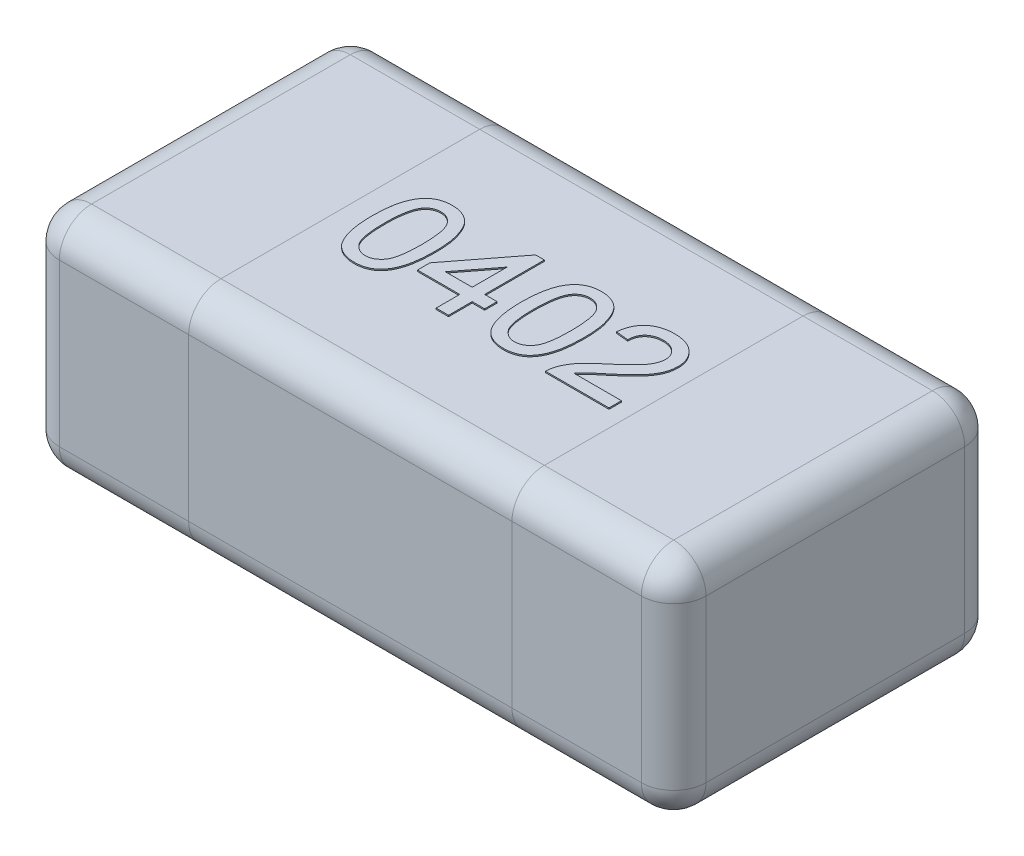
from build123d import *

# Parameters (mm, degrees)
SKETCH1_W      = 1
SKETCH1_H      = 0.5
EXTRUDE1_DEPTH = 0.35
FILLET1_R      = 0.05
EXTRUDE2_DEPTH = 0.002


with BuildPart() as part:
    # Sketch1 → Extrude1 (new body)
    with BuildSketch(Plane(origin=(0, 0, 0), x_dir=(1, 0, 0), z_dir=(0, 1, 0))):
        Rectangle(SKETCH1_W, SKETCH1_H)
    extrude(amount=EXTRUDE1_DEPTH)

    # Fillet1
    fillet1_edges = [part.edges().sort_by_distance(p)[0] for p in [
        (0.5, 0.35, 0),
        (0, 0.35, -0.25),
        (-0.5, 0.35, 0),
        (0, 0, -0.25),
        (0.5, 0, 0),
        (0, 0, 0.25),
        (-0.5, 0, 0),
        (0, 0.35, 0.25),
        (-0.5, 0.175, -0.25),
        (0.5, 0.175, -0.25),
        (0.5, 0.175, 0.25),
        (-0.5, 0.175, 0.25),
    ]]
    fillet(fillet1_edges, radius=FILLET1_R)

    # Sketch3 → Extrude2 (add)
    with BuildSketch(Plane(origin=(0, 0.35, 0), x_dir=(1, 0, 0), z_dir=(0, 1, 0))):
        with BuildLine():
            add(Edge.make_bspline(
                [(-0.215384615, -0.001021635), (-0.21536524, 0.001122003), (-0.215327293, 0.005320487), (-0.215091917, 0.011463622), (-0.21468097, 0.017297504), (-0.214067539, 0.022817065), (-0.213341122, 0.028034764), (-0.212396775, 0.032943155), (-0.211334247, 0.037553251), (-0.210059405, 0.041860246), (-0.20865877, 0.045901174), (-0.207069705, 0.04966955), (-0.205281792, 0.053161381), (-0.203382895, 0.056412877), (-0.201273053, 0.059373466), (-0.19907961, 0.062126232), (-0.196643162, 0.064570222), (-0.19406502, 0.06676832), (-0.191307221, 0.068708013), (-0.188384356, 0.070381735), (-0.185307672, 0.07185951), (-0.182018531, 0.072971978), (-0.178585214, 0.073878876), (-0.174981294, 0.074546001), (-0.171202799, 0.074939294), (-0.168620729, 0.074979536), (-0.167307692, 0.075)],
                knots=[0, 0, 0, 0, 6.431e-06, 1.2595e-05, 1.844e-05, 2.3971e-05, 2.9254e-05, 3.4239e-05, 3.8962e-05, 4.344e-05, 4.7707e-05, 5.1787e-05, 5.5698e-05, 5.947e-05, 6.3071e-05, 6.6596e-05, 7.0016e-05, 7.3406e-05, 7.6749e-05, 8.0114e-05, 8.3502e-05, 8.697e-05, 9.0512e-05, 9.4149e-05, 9.7955e-05, 0.000101893, 0.000101893, 0.000101893, 0.000101893], degree=3))
            add(Edge.make_bspline(
                [(-0.167307692, 0.075), (-0.165381297, 0.074943365), (-0.161596815, 0.074832104), (-0.156071453, 0.073924679), (-0.150864154, 0.072372388), (-0.145978304, 0.070278281), (-0.141497424, 0.067618363), (-0.137495809, 0.064384826), (-0.134016624, 0.060611623), (-0.131097837, 0.056254042), (-0.128546526, 0.051432296), (-0.126279998, 0.046124741), (-0.124231122, 0.040337325), (-0.122777195, 0.035156781), (-0.12174011, 0.030684751), (-0.121053643, 0.026996347), (-0.120483737, 0.023016538), (-0.120047112, 0.018754953), (-0.119688871, 0.014216372), (-0.119412219, 0.009397968), (-0.119271789, 0.004287698), (-0.119244699, 0.000781321), (-0.119230769, -0.001021635)],
                knots=[0, 0, 0, 0, 5.777e-06, 1.1349e-05, 1.674e-05, 2.2043e-05, 2.7258e-05, 3.2321e-05, 3.7425e-05, 4.2592e-05, 4.801e-05, 5.377e-05, 5.9891e-05, 6.6416e-05, 6.99e-05, 7.366e-05, 7.7668e-05, 8.1958e-05, 8.651e-05, 9.1325e-05, 9.6435e-05, 0.000101844, 0.000101844, 0.000101844, 0.000101844], degree=3))
            add(Edge.make_bspline(
                [(-0.119230769, -0.001021635), (-0.119250507, -0.003155203), (-0.119289069, -0.00732355), (-0.119518138, -0.013417428), (-0.119953848, -0.019207296), (-0.120489996, -0.024706416), (-0.121301077, -0.029900109), (-0.12217506, -0.034810441), (-0.123255962, -0.039415115), (-0.12451712, -0.043716149), (-0.12593747, -0.047736285), (-0.127495104, -0.051505906), (-0.129220334, -0.055022436), (-0.131164508, -0.058251575), (-0.133238671, -0.061236186), (-0.135458016, -0.063987464), (-0.137869594, -0.066465811), (-0.140470969, -0.068657315), (-0.143209405, -0.070631406), (-0.146139376, -0.072321652), (-0.149248057, -0.073721992), (-0.152514679, -0.074919212), (-0.155972386, -0.075796465), (-0.159593911, -0.076467989), (-0.163392598, -0.07686343), (-0.165984655, -0.07690292), (-0.167307692, -0.076923077)],
                knots=[0, 0, 0, 0, 6.401e-06, 1.2505e-05, 1.829e-05, 2.3818e-05, 2.9075e-05, 3.4055e-05, 3.8778e-05, 4.3256e-05, 4.7495e-05, 5.1563e-05, 5.5487e-05, 5.9233e-05, 6.2859e-05, 6.6384e-05, 6.9826e-05, 7.3215e-05, 7.6576e-05, 7.9941e-05, 8.3343e-05, 8.6794e-05, 9.0365e-05, 9.4031e-05, 9.7837e-05, 0.000101805, 0.000101805, 0.000101805, 0.000101805], degree=3))
            add(Edge.make_bspline(
                [(-0.167307692, -0.076923077), (-0.169042347, -0.076873596), (-0.172424447, -0.076777121), (-0.177363754, -0.076121636), (-0.181999557, -0.074967951), (-0.186370957, -0.073420697), (-0.190428817, -0.071351156), (-0.194192513, -0.068833154), (-0.197737673, -0.065925277), (-0.199778482, -0.063631029), (-0.200811298, -0.062469952)],
                knots=[0, 0, 0, 0, 5.204e-06, 1.0146e-05, 1.4912e-05, 1.9513e-05, 2.4028e-05, 2.8537e-05, 3.308e-05, 3.7736e-05, 3.7736e-05, 3.7736e-05, 3.7736e-05], degree=3))
            add(Edge.make_bspline(
                [(-0.200811298, -0.062469952), (-0.202000093, -0.060755098), (-0.204451439, -0.057218995), (-0.207320527, -0.051189611), (-0.209879805, -0.044552107), (-0.211888368, -0.037176254), (-0.213461574, -0.029120757), (-0.214597822, -0.020369808), (-0.215240826, -0.010927188), (-0.215335604, -0.004398023), (-0.215384615, -0.001021635)],
                knots=[0, 0, 0, 0, 6.251e-06, 1.2889e-05, 1.9965e-05, 2.7576e-05, 3.5785e-05, 4.4573e-05, 5.4032e-05, 6.4161e-05, 6.4161e-05, 6.4161e-05, 6.4161e-05], degree=3))
        make_face()
        with BuildLine():
            add(Edge.make_bspline(
                [(-0.196153846, -0.000961538), (-0.196134752, -0.003846584), (-0.1960982, -0.009369199), (-0.195716327, -0.017259208), (-0.195058949, -0.024377073), (-0.194189852, -0.030712939), (-0.193042293, -0.036275377), (-0.191601396, -0.041050211), (-0.189977162, -0.045094751), (-0.187967204, -0.048358867), (-0.185766521, -0.051019598), (-0.183494467, -0.053307912), (-0.181097587, -0.055252927), (-0.178591522, -0.056874673), (-0.175937387, -0.058102553), (-0.173164205, -0.058992522), (-0.170271373, -0.059504686), (-0.168301222, -0.059578275), (-0.167307692, -0.059615385)],
                knots=[0, 0, 0, 0, 8.655e-06, 1.6567e-05, 2.3689e-05, 3.0093e-05, 3.5745e-05, 4.0706e-05, 4.5043e-05, 4.8779e-05, 5.2153e-05, 5.5383e-05, 5.8438e-05, 6.1397e-05, 6.4314e-05, 6.7184e-05, 7.0113e-05, 7.3094e-05, 7.3094e-05, 7.3094e-05, 7.3094e-05], degree=3))
            add(Edge.make_bspline(
                [(-0.167307692, -0.059615385), (-0.166314411, -0.059577464), (-0.164344754, -0.059502268), (-0.161445238, -0.059001397), (-0.158682846, -0.058065613), (-0.156032668, -0.05684207), (-0.153508388, -0.055257289), (-0.15112328, -0.053304927), (-0.148839257, -0.051017971), (-0.14664846, -0.048326314), (-0.144653815, -0.045047107), (-0.142999112, -0.041005862), (-0.141580671, -0.036222665), (-0.140426814, -0.030663062), (-0.139554132, -0.024337213), (-0.138900728, -0.01723909), (-0.1385163, -0.009359233), (-0.138480352, -0.003846597), (-0.138461538, -0.000961538)],
                knots=[0, 0, 0, 0, 2.98e-06, 5.91e-06, 8.789e-06, 1.1706e-05, 1.4649e-05, 1.7704e-05, 2.0934e-05, 2.4331e-05, 2.8093e-05, 3.2402e-05, 3.7392e-05, 4.3044e-05, 4.9418e-05, 5.654e-05, 6.4422e-05, 7.3077e-05, 7.3077e-05, 7.3077e-05, 7.3077e-05], degree=3))
            add(Edge.make_bspline(
                [(-0.138461538, -0.000961538), (-0.13847975, 0.001863491), (-0.138514642, 0.007276142), (-0.138908985, 0.015014149), (-0.139526956, 0.022012544), (-0.140372243, 0.028277777), (-0.141495628, 0.033803048), (-0.142858142, 0.038600117), (-0.144481781, 0.042658756), (-0.146412281, 0.046019733), (-0.148561315, 0.048776646), (-0.150806184, 0.051162994), (-0.153203011, 0.053192505), (-0.15579426, 0.054820609), (-0.15849641, 0.056134103), (-0.161371551, 0.057038082), (-0.164391421, 0.057593459), (-0.166463918, 0.057658982), (-0.167518029, 0.057692308)],
                knots=[0, 0, 0, 0, 8.474e-06, 1.6237e-05, 2.3236e-05, 2.9547e-05, 3.5192e-05, 4.0137e-05, 4.4489e-05, 4.8272e-05, 5.1722e-05, 5.4953e-05, 5.8088e-05, 6.1114e-05, 6.4111e-05, 6.7076e-05, 7.0129e-05, 7.329e-05, 7.329e-05, 7.329e-05, 7.329e-05], degree=3))
            add(Edge.make_bspline(
                [(-0.167518029, 0.057692308), (-0.168511496, 0.057666233), (-0.170470487, 0.057614817), (-0.173338706, 0.057124054), (-0.176056884, 0.056303389), (-0.178656161, 0.055191718), (-0.181071649, 0.053695629), (-0.18339914, 0.051948838), (-0.185529622, 0.049820569), (-0.186813432, 0.048229508), (-0.187469952, 0.047415865)],
                knots=[0, 0, 0, 0, 2.979e-06, 5.873e-06, 8.697e-06, 1.1482e-05, 1.4327e-05, 1.72e-05, 2.0196e-05, 2.3331e-05, 2.3331e-05, 2.3331e-05, 2.3331e-05], degree=3))
            add(Edge.make_bspline(
                [(-0.187469952, 0.047415865), (-0.188184701, 0.046220876), (-0.189694102, 0.043697311), (-0.191383033, 0.03931125), (-0.192874969, 0.034298818), (-0.194103326, 0.028582894), (-0.194991956, 0.022173284), (-0.195693496, 0.01507743), (-0.196057919, 0.007285427), (-0.196120988, 0.001863295), (-0.196153846, -0.000961538)],
                knots=[0, 0, 0, 0, 4.171e-06, 8.807e-06, 1.4046e-05, 1.9857e-05, 2.6324e-05, 3.3449e-05, 4.1242e-05, 4.9717e-05, 4.9717e-05, 4.9717e-05, 4.9717e-05], degree=3))
        make_face(mode=Mode.SUBTRACT)
        Polygon((-0.042307692, -0.075), (-0.042307692, -0.038461538), (-0.107692308, -0.038461538), (-0.107692308, -0.019230769), (-0.036538462, 0.073076923), (-0.023076923, 0.073076923), (-0.023076923, -0.019230769), (-0.003846154, -0.019230769), (-0.003846154, -0.038461538), (-0.023076923, -0.038461538), (-0.023076923, -0.075), align=None)
        Polygon((-0.042307692, -0.019230769), (-0.042307692, 0.034795673), (-0.083954327, -0.019230769), align=None, mode=Mode.SUBTRACT)
        with BuildLine():
            add(Edge.make_bspline(
                [(0.015384615, -0.001021635), (0.01540399, 0.001122003), (0.015441938, 0.005320487), (0.015677314, 0.011463622), (0.016088261, 0.017297504), (0.016701692, 0.022817065), (0.017428109, 0.028034764), (0.018372456, 0.032943155), (0.019434984, 0.037553251), (0.020709826, 0.041860246), (0.022110461, 0.045901174), (0.023699525, 0.04966955), (0.025487439, 0.053161381), (0.027386336, 0.056412877), (0.029496178, 0.059373466), (0.031689621, 0.062126232), (0.034126069, 0.064570222), (0.036704211, 0.06676832), (0.03946201, 0.068708013), (0.042384875, 0.070381735), (0.045461558, 0.07185951), (0.0487507, 0.072971978), (0.052184016, 0.073878876), (0.055787937, 0.074546001), (0.059566432, 0.074939294), (0.062148502, 0.074979536), (0.063461538, 0.075)],
                knots=[0, 0, 0, 0, 6.431e-06, 1.2595e-05, 1.844e-05, 2.3971e-05, 2.9254e-05, 3.4239e-05, 3.8962e-05, 4.344e-05, 4.7707e-05, 5.1787e-05, 5.5698e-05, 5.947e-05, 6.3071e-05, 6.6596e-05, 7.0016e-05, 7.3406e-05, 7.6749e-05, 8.0114e-05, 8.3502e-05, 8.697e-05, 9.0512e-05, 9.4149e-05, 9.7955e-05, 0.000101893, 0.000101893, 0.000101893, 0.000101893], degree=3))
            add(Edge.make_bspline(
                [(0.063461538, 0.075), (0.065387934, 0.074943365), (0.069172416, 0.074832104), (0.074697778, 0.073924679), (0.079905076, 0.072372388), (0.084790927, 0.070278281), (0.089271807, 0.067618363), (0.093273422, 0.064384826), (0.096752607, 0.060611623), (0.099671394, 0.056254042), (0.102222704, 0.051432296), (0.104489233, 0.046124741), (0.106538109, 0.040337325), (0.107992036, 0.035156781), (0.10902912, 0.030684751), (0.109715588, 0.026996347), (0.110285494, 0.023016538), (0.110722119, 0.018754953), (0.111080359, 0.014216372), (0.111357012, 0.009397968), (0.111497442, 0.004287698), (0.111524532, 0.000781321), (0.111538462, -0.001021635)],
                knots=[0, 0, 0, 0, 5.777e-06, 1.1349e-05, 1.674e-05, 2.2043e-05, 2.7258e-05, 3.2321e-05, 3.7425e-05, 4.2592e-05, 4.801e-05, 5.377e-05, 5.9891e-05, 6.6416e-05, 6.99e-05, 7.366e-05, 7.7668e-05, 8.1958e-05, 8.651e-05, 9.1325e-05, 9.6435e-05, 0.000101844, 0.000101844, 0.000101844, 0.000101844], degree=3))
            add(Edge.make_bspline(
                [(0.111538462, -0.001021635), (0.111518724, -0.003155203), (0.111480162, -0.00732355), (0.111251093, -0.013417428), (0.110815383, -0.019207296), (0.110279235, -0.024706416), (0.109468154, -0.029900109), (0.108594171, -0.034810441), (0.107513269, -0.039415115), (0.106252111, -0.043716149), (0.10483176, -0.047736285), (0.103274126, -0.051505906), (0.101548897, -0.055022436), (0.099604723, -0.058251575), (0.097530559, -0.061236186), (0.095311215, -0.063987464), (0.092899636, -0.066465811), (0.090298262, -0.068657315), (0.087559826, -0.070631406), (0.084629855, -0.072321652), (0.081521174, -0.073721992), (0.078254552, -0.074919212), (0.074796845, -0.075796465), (0.07117532, -0.076467989), (0.067376633, -0.07686343), (0.064784575, -0.07690292), (0.063461538, -0.076923077)],
                knots=[0, 0, 0, 0, 6.401e-06, 1.2505e-05, 1.829e-05, 2.3818e-05, 2.9075e-05, 3.4055e-05, 3.8778e-05, 4.3256e-05, 4.7495e-05, 5.1563e-05, 5.5487e-05, 5.9233e-05, 6.2859e-05, 6.6384e-05, 6.9826e-05, 7.3215e-05, 7.6576e-05, 7.9941e-05, 8.3343e-05, 8.6794e-05, 9.0365e-05, 9.4031e-05, 9.7837e-05, 0.000101805, 0.000101805, 0.000101805, 0.000101805], degree=3))
            add(Edge.make_bspline(
                [(0.063461538, -0.076923077), (0.061726884, -0.076873596), (0.058344784, -0.076777121), (0.053405477, -0.076121636), (0.048769674, -0.074967951), (0.044398274, -0.073420697), (0.040340414, -0.071351156), (0.036576718, -0.068833154), (0.033031558, -0.065925277), (0.030990749, -0.063631029), (0.029957933, -0.062469952)],
                knots=[0, 0, 0, 0, 5.204e-06, 1.0146e-05, 1.4912e-05, 1.9513e-05, 2.4028e-05, 2.8537e-05, 3.308e-05, 3.7736e-05, 3.7736e-05, 3.7736e-05, 3.7736e-05], degree=3))
            add(Edge.make_bspline(
                [(0.029957933, -0.062469952), (0.028769138, -0.060755098), (0.026317792, -0.057218995), (0.023448703, -0.051189611), (0.020889426, -0.044552107), (0.018880862, -0.037176254), (0.017307656, -0.029120757), (0.016171409, -0.020369808), (0.015528405, -0.010927188), (0.015433627, -0.004398023), (0.015384615, -0.001021635)],
                knots=[0, 0, 0, 0, 6.251e-06, 1.2889e-05, 1.9965e-05, 2.7576e-05, 3.5785e-05, 4.4573e-05, 5.4032e-05, 6.4161e-05, 6.4161e-05, 6.4161e-05, 6.4161e-05], degree=3))
        make_face()
        with BuildLine():
            add(Edge.make_bspline(
                [(0.034615385, -0.000961538), (0.034634479, -0.003846584), (0.034671031, -0.009369199), (0.035052903, -0.017259208), (0.035710281, -0.024377073), (0.036579378, -0.030712939), (0.037726938, -0.036275377), (0.039167835, -0.041050211), (0.040792069, -0.045094751), (0.042802027, -0.048358867), (0.04500271, -0.051019598), (0.047274764, -0.053307912), (0.049671644, -0.055252927), (0.052177709, -0.056874673), (0.054831844, -0.058102553), (0.057605026, -0.058992522), (0.060497858, -0.059504686), (0.062468008, -0.059578275), (0.063461538, -0.059615385)],
                knots=[0, 0, 0, 0, 8.655e-06, 1.6567e-05, 2.3689e-05, 3.0093e-05, 3.5745e-05, 4.0706e-05, 4.5043e-05, 4.8779e-05, 5.2153e-05, 5.5383e-05, 5.8438e-05, 6.1397e-05, 6.4314e-05, 6.7184e-05, 7.0113e-05, 7.3094e-05, 7.3094e-05, 7.3094e-05, 7.3094e-05], degree=3))
            add(Edge.make_bspline(
                [(0.063461538, -0.059615385), (0.06445482, -0.059577464), (0.066424477, -0.059502268), (0.069323993, -0.059001397), (0.072086385, -0.058065613), (0.074736563, -0.05684207), (0.077260843, -0.055257289), (0.079645951, -0.053304927), (0.081929974, -0.051017971), (0.084120771, -0.048326314), (0.086115416, -0.045047107), (0.087770119, -0.041005862), (0.08918856, -0.036222665), (0.090342417, -0.030663062), (0.091215099, -0.024337213), (0.091868502, -0.01723909), (0.092252931, -0.009359233), (0.092288879, -0.003846597), (0.092307692, -0.000961538)],
                knots=[0, 0, 0, 0, 2.98e-06, 5.91e-06, 8.789e-06, 1.1706e-05, 1.4649e-05, 1.7704e-05, 2.0934e-05, 2.4331e-05, 2.8093e-05, 3.2402e-05, 3.7392e-05, 4.3044e-05, 4.9418e-05, 5.654e-05, 6.4422e-05, 7.3077e-05, 7.3077e-05, 7.3077e-05, 7.3077e-05], degree=3))
            add(Edge.make_bspline(
                [(0.092307692, -0.000961538), (0.092289481, 0.001863491), (0.092254589, 0.007276142), (0.091860246, 0.015014149), (0.091242275, 0.022012544), (0.090396988, 0.028277777), (0.089273602, 0.033803048), (0.087911089, 0.038600117), (0.08628745, 0.042658756), (0.084356949, 0.046019733), (0.082207916, 0.048776646), (0.079963047, 0.051162994), (0.07756622, 0.053192505), (0.074974971, 0.054820609), (0.07227282, 0.056134103), (0.06939768, 0.057038082), (0.06637781, 0.057593459), (0.064305312, 0.057658982), (0.063251202, 0.057692308)],
                knots=[0, 0, 0, 0, 8.474e-06, 1.6237e-05, 2.3236e-05, 2.9547e-05, 3.5192e-05, 4.0137e-05, 4.4489e-05, 4.8272e-05, 5.1722e-05, 5.4953e-05, 5.8088e-05, 6.1114e-05, 6.4111e-05, 6.7076e-05, 7.0129e-05, 7.329e-05, 7.329e-05, 7.329e-05, 7.329e-05], degree=3))
            add(Edge.make_bspline(
                [(0.063251202, 0.057692308), (0.062257734, 0.057666233), (0.060298744, 0.057614817), (0.057430524, 0.057124054), (0.054712347, 0.056303389), (0.052113069, 0.055191718), (0.049697582, 0.053695629), (0.047370091, 0.051948838), (0.045239608, 0.049820569), (0.043955798, 0.048229508), (0.043299279, 0.047415865)],
                knots=[0, 0, 0, 0, 2.979e-06, 5.873e-06, 8.697e-06, 1.1482e-05, 1.4327e-05, 1.72e-05, 2.0196e-05, 2.3331e-05, 2.3331e-05, 2.3331e-05, 2.3331e-05], degree=3))
            add(Edge.make_bspline(
                [(0.043299279, 0.047415865), (0.042584529, 0.046220876), (0.041075129, 0.043697311), (0.039386197, 0.03931125), (0.037894262, 0.034298818), (0.036665905, 0.028582894), (0.035777274, 0.022173284), (0.035075735, 0.01507743), (0.034711312, 0.007285427), (0.034648242, 0.001863295), (0.034615385, -0.000961538)],
                knots=[0, 0, 0, 0, 4.171e-06, 8.807e-06, 1.4046e-05, 1.9857e-05, 2.6324e-05, 3.3449e-05, 4.1242e-05, 4.9717e-05, 4.9717e-05, 4.9717e-05, 4.9717e-05], degree=3))
        make_face(mode=Mode.SUBTRACT)
        with BuildLine():
            Line((0.225, -0.055769231), (0.225, -0.075))
            Line((0.225, -0.075), (0.126923077, -0.075))
            add(Edge.make_bspline(
                [(0.126923077, -0.075), (0.126921069, -0.073857061), (0.12691706, -0.071575015), (0.127303219, -0.068200013), (0.127908021, -0.064869783), (0.128591871, -0.062734239), (0.128936298, -0.061658654)],
                knots=[0, 0, 0, 0, 3.426e-06, 6.841e-06, 1.0176e-05, 1.3561e-05, 1.3561e-05, 1.3561e-05, 1.3561e-05], degree=3))
            add(Edge.make_bspline(
                [(0.128936298, -0.061658654), (0.129572684, -0.059901276), (0.130868472, -0.056322964), (0.133493751, -0.051159961), (0.136581699, -0.046028182), (0.139588252, -0.04185019), (0.142341605, -0.038512266), (0.14465065, -0.035900727), (0.147209495, -0.033227509), (0.150016092, -0.030493101), (0.153043427, -0.027679792), (0.156295632, -0.0247782), (0.159811111, -0.021842401), (0.162265283, -0.019896431), (0.163521635, -0.01890024)],
                knots=[0, 0, 0, 0, 5.603e-06, 1.1408e-05, 1.7339e-05, 2.356e-05, 2.6827e-05, 3.0318e-05, 3.4016e-05, 3.7925e-05, 4.2071e-05, 4.6413e-05, 5.0999e-05, 5.5809e-05, 5.5809e-05, 5.5809e-05, 5.5809e-05], degree=3))
            add(Edge.make_bspline(
                [(0.163521635, -0.01890024), (0.1654517, -0.017275735), (0.169168165, -0.014147648), (0.174416395, -0.009505855), (0.179209799, -0.005195689), (0.183472047, -0.001141602), (0.187238, 0.002617081), (0.1905165, 0.006071846), (0.193335758, 0.009211911), (0.195661355, 0.012150933), (0.197623532, 0.014926186), (0.199286304, 0.017633275), (0.200672004, 0.020319486), (0.201826106, 0.022976319), (0.202738903, 0.025615135), (0.203361104, 0.028243623), (0.203783059, 0.030835702), (0.203825276, 0.0325605), (0.203846154, 0.033413462)],
                knots=[0, 0, 0, 0, 7.568e-06, 1.4572e-05, 2.1018e-05, 2.6906e-05, 3.2217e-05, 3.6978e-05, 4.1193e-05, 4.4872e-05, 4.8215e-05, 5.1384e-05, 5.4395e-05, 5.7275e-05, 6.0069e-05, 6.2758e-05, 6.5371e-05, 6.7928e-05, 6.7928e-05, 6.7928e-05, 6.7928e-05], degree=3))
            add(Edge.make_bspline(
                [(0.203846154, 0.033413462), (0.203825274, 0.034256471), (0.203784308, 0.035910411), (0.20339563, 0.03833094), (0.202854559, 0.040661969), (0.201979812, 0.042861531), (0.2009386, 0.044994766), (0.199602994, 0.046994266), (0.198057972, 0.048909863), (0.196289053, 0.050691052), (0.194356979, 0.052362092), (0.192198162, 0.053751132), (0.189954391, 0.055001681), (0.18754826, 0.056007195), (0.184983678, 0.056745562), (0.182279313, 0.057281426), (0.179435596, 0.057621193), (0.177494958, 0.057668243), (0.176502404, 0.057692308)],
                knots=[0, 0, 0, 0, 2.527e-06, 4.958e-06, 7.341e-06, 9.69e-06, 1.2042e-05, 1.445e-05, 1.6886e-05, 1.9414e-05, 2.1973e-05, 2.4531e-05, 2.71e-05, 2.9672e-05, 3.2335e-05, 3.5092e-05, 3.7936e-05, 4.0913e-05, 4.0913e-05, 4.0913e-05, 4.0913e-05], degree=3))
            add(Edge.make_bspline(
                [(0.176502404, 0.057692308), (0.175459753, 0.057668362), (0.173419208, 0.0576215), (0.170436479, 0.057280378), (0.167604894, 0.05675919), (0.164931212, 0.055962339), (0.162418689, 0.054958502), (0.160077555, 0.053694939), (0.157870321, 0.052268604), (0.155866501, 0.050579931), (0.154054473, 0.048707538), (0.152445813, 0.046669068), (0.151127759, 0.044425183), (0.150039255, 0.042025221), (0.149164007, 0.039461638), (0.148528606, 0.036714835), (0.148182182, 0.033792744), (0.148112518, 0.031791696), (0.148076923, 0.030769231)],
                knots=[0, 0, 0, 0, 3.127e-06, 6.12e-06, 8.996e-06, 1.1753e-05, 1.4476e-05, 1.7098e-05, 1.9723e-05, 2.2347e-05, 2.4939e-05, 2.753e-05, 3.0117e-05, 3.2725e-05, 3.5424e-05, 3.823e-05, 4.1167e-05, 4.4236e-05, 4.4236e-05, 4.4236e-05, 4.4236e-05], degree=3))
            Line((0.148076923, 0.030769231), (0.128846154, 0.032692308))
            add(Edge.make_bspline(
                [(0.128846154, 0.032692308), (0.129042912, 0.034368316), (0.129425688, 0.037628847), (0.13037913, 0.042351176), (0.131717678, 0.046744295), (0.133319362, 0.050869455), (0.135327225, 0.054656431), (0.137596941, 0.058183555), (0.140273966, 0.06133896), (0.143231368, 0.064222108), (0.14650155, 0.066762921), (0.150053792, 0.068982673), (0.15388647, 0.070839359), (0.157978237, 0.072376617), (0.162338487, 0.073542974), (0.166961051, 0.074379362), (0.171853364, 0.074894921), (0.17520906, 0.074964474), (0.176923077, 0.075)],
                knots=[0, 0, 0, 0, 5.061e-06, 9.846e-06, 1.4428e-05, 1.8825e-05, 2.3099e-05, 2.7266e-05, 3.1383e-05, 3.5484e-05, 3.9638e-05, 4.3781e-05, 4.8028e-05, 5.2392e-05, 5.6875e-05, 6.1549e-05, 6.6473e-05, 7.1615e-05, 7.1615e-05, 7.1615e-05, 7.1615e-05], degree=3))
            add(Edge.make_bspline(
                [(0.176923077, 0.075), (0.178657609, 0.074970298), (0.182036489, 0.074912439), (0.186960059, 0.07432042), (0.191605584, 0.073398356), (0.195990093, 0.072113282), (0.200087683, 0.070428166), (0.203901505, 0.068369335), (0.207449145, 0.065956873), (0.210671327, 0.063161818), (0.213576854, 0.060110548), (0.216123119, 0.056854184), (0.21825192, 0.053406639), (0.220064461, 0.049814905), (0.22140889, 0.046003091), (0.222354317, 0.042023019), (0.222996763, 0.037871287), (0.223049848, 0.035038552), (0.223076923, 0.03359375)],
                knots=[0, 0, 0, 0, 5.201e-06, 1.0132e-05, 1.4853e-05, 1.9397e-05, 2.3817e-05, 2.8119e-05, 3.2378e-05, 3.666e-05, 4.089e-05, 4.5001e-05, 4.9037e-05, 5.3028e-05, 5.7048e-05, 6.1129e-05, 6.5289e-05, 6.962e-05, 6.962e-05, 6.962e-05, 6.962e-05], degree=3))
            add(Edge.make_bspline(
                [(0.223076923, 0.03359375), (0.223035579, 0.03210938), (0.222952801, 0.029137364), (0.222306703, 0.024695077), (0.221201221, 0.020300998), (0.219735648, 0.01590165), (0.21773337, 0.011479571), (0.215203832, 0.006973759), (0.212065664, 0.002367569), (0.209047626, -0.001548204), (0.206238322, -0.00483061), (0.20374814, -0.007532221), (0.200867143, -0.010402503), (0.197703409, -0.013540859), (0.194127905, -0.016835902), (0.190243364, -0.020386306), (0.185964751, -0.024098636), (0.18299456, -0.026634721), (0.181460337, -0.027944712)],
                knots=[0, 0, 0, 0, 4.452e-06, 8.914e-06, 1.3432e-05, 1.8031e-05, 2.2806e-05, 2.7972e-05, 3.3514e-05, 3.9512e-05, 4.2794e-05, 4.6473e-05, 5.0531e-05, 5.4993e-05, 5.9841e-05, 6.5116e-05, 7.0781e-05, 7.6833e-05, 7.6833e-05, 7.6833e-05, 7.6833e-05], degree=3))
            add(Edge.make_bspline(
                [(0.181460337, -0.027944712), (0.180146506, -0.02901431), (0.177641234, -0.031053868), (0.174076998, -0.034010672), (0.170884527, -0.03672198), (0.167989166, -0.039099356), (0.16549636, -0.04125779), (0.163318306, -0.043102752), (0.161534132, -0.044727006), (0.158817151, -0.047194282), (0.155375862, -0.050711133), (0.152840174, -0.05412836), (0.151622596, -0.055769231)],
                knots=[0, 0, 0, 0, 5.082e-06, 9.692e-06, 1.3893e-05, 1.7648e-05, 2.093e-05, 2.3785e-05, 2.621e-05, 2.8167e-05, 3.4797e-05, 4.0922e-05, 4.0922e-05, 4.0922e-05, 4.0922e-05], degree=3))
            Line((0.151622596, -0.055769231), (0.225, -0.055769231))
        make_face()
    extrude(amount=EXTRUDE2_DEPTH)


solid = part.part
